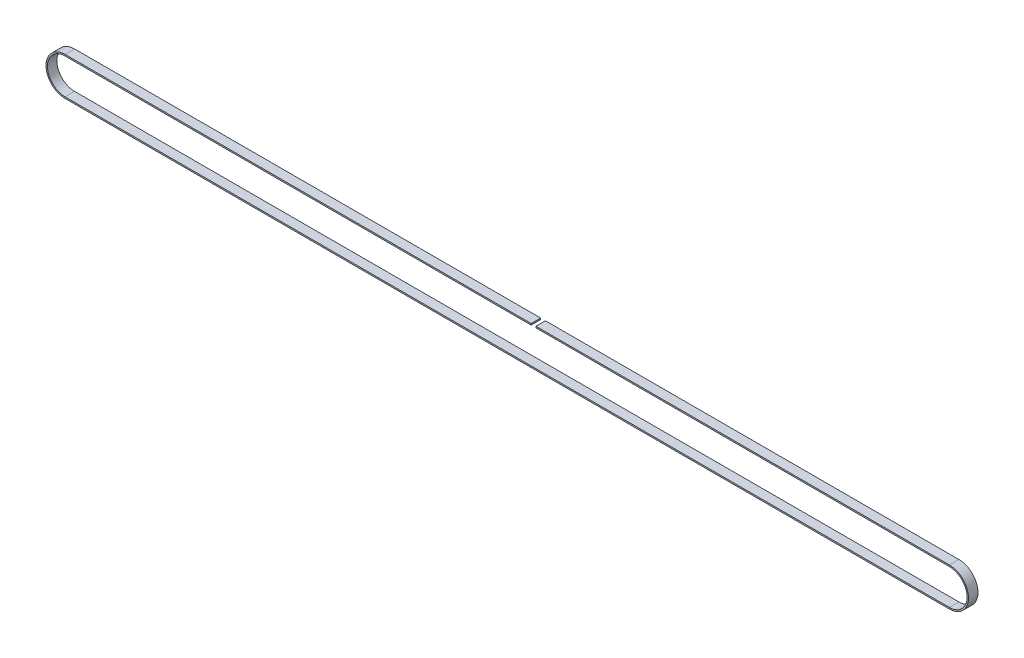
from build123d import *

# Parameters (mm, degrees)
EXTRUDE_1_DEPTH     = 10
CUT_EXTRUDE_1_REACH = 42.24
SKETCH_2_W          = 5
SKETCH_2_H          = 10


with BuildPart() as part:
    # 草圖1 → 伸長1 (new body)
    with BuildSketch(Plane.XY):
        with BuildLine():
            Line((-466, 20.12), (466, 20.12))
            ThreePointArc((466, 20.12), (486.12, 0), (466, -20.12))
            Line((466, -20.12), (-466, -20.12))
            ThreePointArc((-466, -20.12), (-486.12, 0), (-466, 20.12))
        make_face()
        with BuildLine():
            Line((-466, 18.62), (466, 18.62))
            ThreePointArc((466, 18.62), (484.62, 0), (466, -18.62))
            Line((466, -18.62), (-466, -18.62))
            ThreePointArc((-466, -18.62), (-484.62, 0), (-466, 18.62))
        make_face(mode=Mode.SUBTRACT)
    extrude(amount=EXTRUDE_1_DEPTH)

    # 草圖2 → 除料-伸長1 (cut, up to next)
    with BuildSketch(Plane(origin=(0, 20.12, 0), x_dir=(1, 0, 0), z_dir=(0, 1, 0)), mode=Mode.PRIVATE) as cut_extrude_1_sk1:
        with Locations((27.677656209, -5)):
            Rectangle(SKETCH_2_W, SKETCH_2_H)
    cut_extrude_1_tool1 = extrude(cut_extrude_1_sk1.sketch, amount=-CUT_EXTRUDE_1_REACH, mode=Mode.PRIVATE) & part.part
    add(cut_extrude_1_tool1.solids().sort_by_distance((27.677656, 20.12, 5))[0], mode=Mode.SUBTRACT)


solid = part.part
